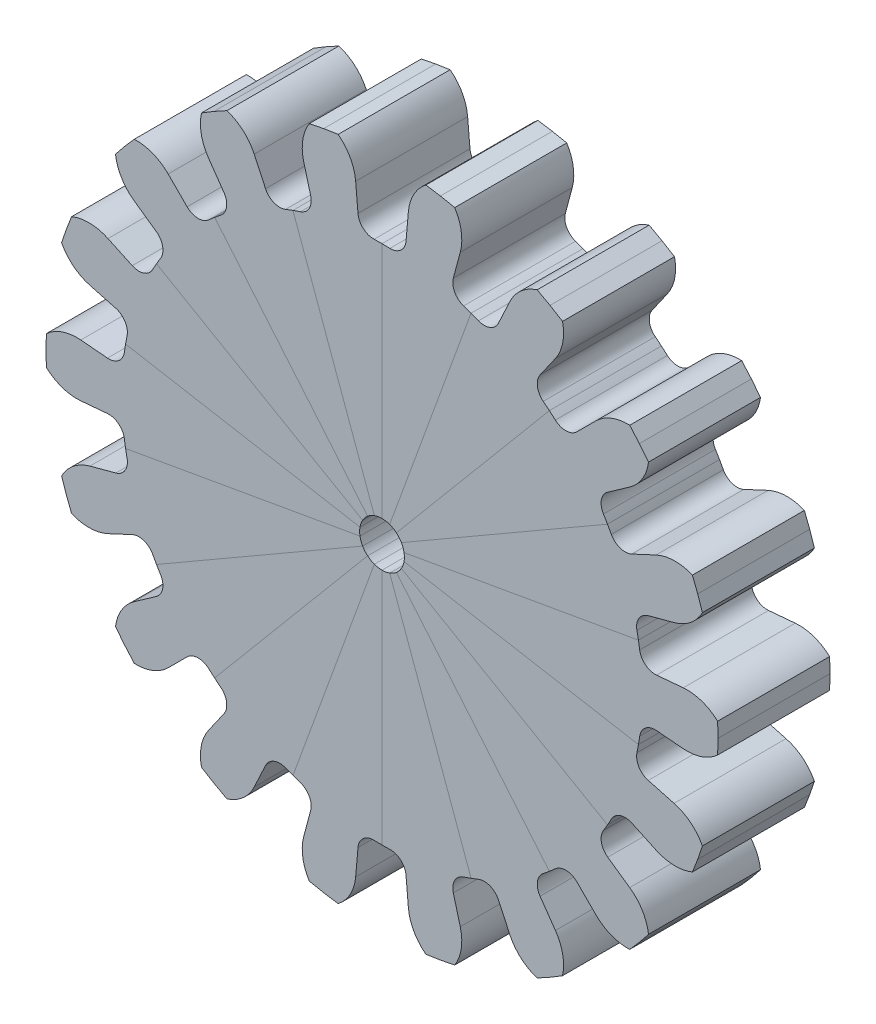
from build123d import *

# Parameters (mm, degrees)
BOSS_EXTRU_4_DEPTH           = 5
CONG_1_R                     = 0.7
R_P_TITION_CIRCULAIRE1_COUNT = 18
ESQUISSE5_R                  = 2.5
ENL_V_MAT_EXTRU_1_DEPTH      = 3
ESQUISSE6_R                  = 1
ENL_V_MAT_EXTRU_2_DEPTH      = 2


with BuildPart() as part:
    # Esquisse4 → Boss.-Extru.4 (new body)
    with BuildSketch(Plane.XY):
        with BuildLine():
            ThreePointArc((11.580763365, -1.013185509), (11.525546513, -1.517366985), (11.448390129, -2.018660065))
            Line((11.448390129, -2.018660065), (0, 0))
            Line((0, 0), (11.448390129, 2.018660065))
            ThreePointArc((11.448390129, 2.018660065), (11.525546513, 1.517366985), (11.580763365, 1.013185509))
            Line((11.580763365, 1.013185509), (13.448628424, 1.176602527))
            ThreePointArc((13.448628424, 1.176602527), (14.27213386, 1.077180815), (14.985723324, 0.65429081))
            Line((14.985723324, 0.65429081), (15, 0))
            Line((15, 0), (14.985723324, -0.65429081))
            ThreePointArc((14.985723324, -0.65429081), (14.27213386, -1.077180815), (13.448628424, -1.176602527))
            Line((13.448628424, -1.176602527), (11.580763365, -1.013185509))
        make_face()
    extrude(amount=BOSS_EXTRU_4_DEPTH)

    # Congé1
    cong_1_edges = [part.edges().sort_by_distance(p)[0] for p in [
        (11.580763365, 1.013185509, 2.5),
        (11.580763365, -1.013185509, 2.5),
    ]]
    fillet(cong_1_edges, radius=CONG_1_R)


with BuildPart() as r_p_tition_circulaire1_1:
    # Répétition circulaire1: pattern copy
    add(part.part.rotate(Axis((0, 0, 0), (0, 0, 1)), 1 * 360 / R_P_TITION_CIRCULAIRE1_COUNT))


with BuildPart() as r_p_tition_circulaire1_2:
    # Répétition circulaire1: pattern copy
    add(part.part.rotate(Axis((0, 0, 0), (0, 0, 1)), 2 * 360 / R_P_TITION_CIRCULAIRE1_COUNT))


with BuildPart() as r_p_tition_circulaire1_3:
    # Répétition circulaire1: pattern copy
    add(part.part.rotate(Axis((0, 0, 0), (0, 0, 1)), 3 * 360 / R_P_TITION_CIRCULAIRE1_COUNT))


with BuildPart() as r_p_tition_circulaire1_4:
    # Répétition circulaire1: pattern copy
    add(part.part.rotate(Axis((0, 0, 0), (0, 0, 1)), 4 * 360 / R_P_TITION_CIRCULAIRE1_COUNT))


with BuildPart() as r_p_tition_circulaire1_5:
    # Répétition circulaire1: pattern copy
    add(part.part.rotate(Axis((0, 0, 0), (0, 0, 1)), 5 * 360 / R_P_TITION_CIRCULAIRE1_COUNT))


with BuildPart() as r_p_tition_circulaire1_6:
    # Répétition circulaire1: pattern copy
    add(part.part.rotate(Axis((0, 0, 0), (0, 0, 1)), 6 * 360 / R_P_TITION_CIRCULAIRE1_COUNT))


with BuildPart() as r_p_tition_circulaire1_7:
    # Répétition circulaire1: pattern copy
    add(part.part.rotate(Axis((0, 0, 0), (0, 0, 1)), 7 * 360 / R_P_TITION_CIRCULAIRE1_COUNT))


with BuildPart() as r_p_tition_circulaire1_8:
    # Répétition circulaire1: pattern copy
    add(part.part.rotate(Axis((0, 0, 0), (0, 0, 1)), 8 * 360 / R_P_TITION_CIRCULAIRE1_COUNT))


with BuildPart() as r_p_tition_circulaire1_9:
    # Répétition circulaire1: pattern copy
    add(part.part.rotate(Axis((0, 0, 0), (0, 0, 1)), 9 * 360 / R_P_TITION_CIRCULAIRE1_COUNT))


with BuildPart() as r_p_tition_circulaire1_10:
    # Répétition circulaire1: pattern copy
    add(part.part.rotate(Axis((0, 0, 0), (0, 0, 1)), 10 * 360 / R_P_TITION_CIRCULAIRE1_COUNT))


with BuildPart() as r_p_tition_circulaire1_11:
    # Répétition circulaire1: pattern copy
    add(part.part.rotate(Axis((0, 0, 0), (0, 0, 1)), 11 * 360 / R_P_TITION_CIRCULAIRE1_COUNT))


with BuildPart() as r_p_tition_circulaire1_12:
    # Répétition circulaire1: pattern copy
    add(part.part.rotate(Axis((0, 0, 0), (0, 0, 1)), 12 * 360 / R_P_TITION_CIRCULAIRE1_COUNT))


with BuildPart() as r_p_tition_circulaire1_13:
    # Répétition circulaire1: pattern copy
    add(part.part.rotate(Axis((0, 0, 0), (0, 0, 1)), 13 * 360 / R_P_TITION_CIRCULAIRE1_COUNT))


with BuildPart() as r_p_tition_circulaire1_14:
    # Répétition circulaire1: pattern copy
    add(part.part.rotate(Axis((0, 0, 0), (0, 0, 1)), 14 * 360 / R_P_TITION_CIRCULAIRE1_COUNT))


with BuildPart() as r_p_tition_circulaire1_15:
    # Répétition circulaire1: pattern copy
    add(part.part.rotate(Axis((0, 0, 0), (0, 0, 1)), 15 * 360 / R_P_TITION_CIRCULAIRE1_COUNT))


with BuildPart() as r_p_tition_circulaire1_16:
    # Répétition circulaire1: pattern copy
    add(part.part.rotate(Axis((0, 0, 0), (0, 0, 1)), 16 * 360 / R_P_TITION_CIRCULAIRE1_COUNT))


with BuildPart() as r_p_tition_circulaire1_17:
    # Répétition circulaire1: pattern copy
    add(part.part.rotate(Axis((0, 0, 0), (0, 0, 1)), 17 * 360 / R_P_TITION_CIRCULAIRE1_COUNT))


with BuildPart() as enl_v_mat_extru_1_tool:
    # Esquisse5 → Enlèv. mat.-Extru.1 (new body)
    with BuildSketch(Plane(origin=(0, 0, 0), x_dir=(-1, 0, 0), z_dir=(0, 0, -1))):
        Circle(ESQUISSE5_R)
    extrude(amount=-ENL_V_MAT_EXTRU_1_DEPTH)


with BuildPart() as part_1:
    add(part.part)

    # Enlèv. mat.-Extru.1: cut by enl_v_mat_extru_1_tool
    add(enl_v_mat_extru_1_tool.part, mode=Mode.SUBTRACT)


with BuildPart() as r_p_tition_circulaire1_1_1:
    add(r_p_tition_circulaire1_1.part)

    # Enlèv. mat.-Extru.1: cut by enl_v_mat_extru_1_tool
    add(enl_v_mat_extru_1_tool.part, mode=Mode.SUBTRACT)


with BuildPart() as r_p_tition_circulaire1_2_1:
    add(r_p_tition_circulaire1_2.part)

    # Enlèv. mat.-Extru.1: cut by enl_v_mat_extru_1_tool
    add(enl_v_mat_extru_1_tool.part, mode=Mode.SUBTRACT)


with BuildPart() as r_p_tition_circulaire1_3_1:
    add(r_p_tition_circulaire1_3.part)

    # Enlèv. mat.-Extru.1: cut by enl_v_mat_extru_1_tool
    add(enl_v_mat_extru_1_tool.part, mode=Mode.SUBTRACT)


with BuildPart() as r_p_tition_circulaire1_4_1:
    add(r_p_tition_circulaire1_4.part)

    # Enlèv. mat.-Extru.1: cut by enl_v_mat_extru_1_tool
    add(enl_v_mat_extru_1_tool.part, mode=Mode.SUBTRACT)


with BuildPart() as r_p_tition_circulaire1_5_1:
    add(r_p_tition_circulaire1_5.part)

    # Enlèv. mat.-Extru.1: cut by enl_v_mat_extru_1_tool
    add(enl_v_mat_extru_1_tool.part, mode=Mode.SUBTRACT)


with BuildPart() as r_p_tition_circulaire1_6_1:
    add(r_p_tition_circulaire1_6.part)

    # Enlèv. mat.-Extru.1: cut by enl_v_mat_extru_1_tool
    add(enl_v_mat_extru_1_tool.part, mode=Mode.SUBTRACT)


with BuildPart() as r_p_tition_circulaire1_7_1:
    add(r_p_tition_circulaire1_7.part)

    # Enlèv. mat.-Extru.1: cut by enl_v_mat_extru_1_tool
    add(enl_v_mat_extru_1_tool.part, mode=Mode.SUBTRACT)


with BuildPart() as r_p_tition_circulaire1_8_1:
    add(r_p_tition_circulaire1_8.part)

    # Enlèv. mat.-Extru.1: cut by enl_v_mat_extru_1_tool
    add(enl_v_mat_extru_1_tool.part, mode=Mode.SUBTRACT)


with BuildPart() as r_p_tition_circulaire1_9_1:
    add(r_p_tition_circulaire1_9.part)

    # Enlèv. mat.-Extru.1: cut by enl_v_mat_extru_1_tool
    add(enl_v_mat_extru_1_tool.part, mode=Mode.SUBTRACT)


with BuildPart() as r_p_tition_circulaire1_10_1:
    add(r_p_tition_circulaire1_10.part)

    # Enlèv. mat.-Extru.1: cut by enl_v_mat_extru_1_tool
    add(enl_v_mat_extru_1_tool.part, mode=Mode.SUBTRACT)


with BuildPart() as r_p_tition_circulaire1_11_1:
    add(r_p_tition_circulaire1_11.part)

    # Enlèv. mat.-Extru.1: cut by enl_v_mat_extru_1_tool
    add(enl_v_mat_extru_1_tool.part, mode=Mode.SUBTRACT)


with BuildPart() as r_p_tition_circulaire1_12_1:
    add(r_p_tition_circulaire1_12.part)

    # Enlèv. mat.-Extru.1: cut by enl_v_mat_extru_1_tool
    add(enl_v_mat_extru_1_tool.part, mode=Mode.SUBTRACT)


with BuildPart() as r_p_tition_circulaire1_13_1:
    add(r_p_tition_circulaire1_13.part)

    # Enlèv. mat.-Extru.1: cut by enl_v_mat_extru_1_tool
    add(enl_v_mat_extru_1_tool.part, mode=Mode.SUBTRACT)


with BuildPart() as r_p_tition_circulaire1_14_1:
    add(r_p_tition_circulaire1_14.part)

    # Enlèv. mat.-Extru.1: cut by enl_v_mat_extru_1_tool
    add(enl_v_mat_extru_1_tool.part, mode=Mode.SUBTRACT)


with BuildPart() as r_p_tition_circulaire1_15_1:
    add(r_p_tition_circulaire1_15.part)

    # Enlèv. mat.-Extru.1: cut by enl_v_mat_extru_1_tool
    add(enl_v_mat_extru_1_tool.part, mode=Mode.SUBTRACT)


with BuildPart() as r_p_tition_circulaire1_16_1:
    add(r_p_tition_circulaire1_16.part)

    # Enlèv. mat.-Extru.1: cut by enl_v_mat_extru_1_tool
    add(enl_v_mat_extru_1_tool.part, mode=Mode.SUBTRACT)


with BuildPart() as r_p_tition_circulaire1_17_1:
    add(r_p_tition_circulaire1_17.part)

    # Enlèv. mat.-Extru.1: cut by enl_v_mat_extru_1_tool
    add(enl_v_mat_extru_1_tool.part, mode=Mode.SUBTRACT)


with BuildPart() as enl_v_mat_extru_2_tool:
    # Esquisse6 → Enlèv. mat.-Extru.2 (new body)
    with BuildSketch(Plane.XY.offset(5)):
        Circle(ESQUISSE6_R)
    extrude(amount=-ENL_V_MAT_EXTRU_2_DEPTH)


with BuildPart() as part_2:
    add(part_1.part)

    # Enlèv. mat.-Extru.2: cut by enl_v_mat_extru_2_tool
    add(enl_v_mat_extru_2_tool.part, mode=Mode.SUBTRACT)


with BuildPart() as r_p_tition_circulaire1_1_2:
    add(r_p_tition_circulaire1_1_1.part)

    # Enlèv. mat.-Extru.2: cut by enl_v_mat_extru_2_tool
    add(enl_v_mat_extru_2_tool.part, mode=Mode.SUBTRACT)


with BuildPart() as r_p_tition_circulaire1_2_2:
    add(r_p_tition_circulaire1_2_1.part)

    # Enlèv. mat.-Extru.2: cut by enl_v_mat_extru_2_tool
    add(enl_v_mat_extru_2_tool.part, mode=Mode.SUBTRACT)


with BuildPart() as r_p_tition_circulaire1_3_2:
    add(r_p_tition_circulaire1_3_1.part)

    # Enlèv. mat.-Extru.2: cut by enl_v_mat_extru_2_tool
    add(enl_v_mat_extru_2_tool.part, mode=Mode.SUBTRACT)


with BuildPart() as r_p_tition_circulaire1_4_2:
    add(r_p_tition_circulaire1_4_1.part)

    # Enlèv. mat.-Extru.2: cut by enl_v_mat_extru_2_tool
    add(enl_v_mat_extru_2_tool.part, mode=Mode.SUBTRACT)


with BuildPart() as r_p_tition_circulaire1_5_2:
    add(r_p_tition_circulaire1_5_1.part)

    # Enlèv. mat.-Extru.2: cut by enl_v_mat_extru_2_tool
    add(enl_v_mat_extru_2_tool.part, mode=Mode.SUBTRACT)


with BuildPart() as r_p_tition_circulaire1_6_2:
    add(r_p_tition_circulaire1_6_1.part)

    # Enlèv. mat.-Extru.2: cut by enl_v_mat_extru_2_tool
    add(enl_v_mat_extru_2_tool.part, mode=Mode.SUBTRACT)


with BuildPart() as r_p_tition_circulaire1_7_2:
    add(r_p_tition_circulaire1_7_1.part)

    # Enlèv. mat.-Extru.2: cut by enl_v_mat_extru_2_tool
    add(enl_v_mat_extru_2_tool.part, mode=Mode.SUBTRACT)


with BuildPart() as r_p_tition_circulaire1_8_2:
    add(r_p_tition_circulaire1_8_1.part)

    # Enlèv. mat.-Extru.2: cut by enl_v_mat_extru_2_tool
    add(enl_v_mat_extru_2_tool.part, mode=Mode.SUBTRACT)


with BuildPart() as r_p_tition_circulaire1_9_2:
    add(r_p_tition_circulaire1_9_1.part)

    # Enlèv. mat.-Extru.2: cut by enl_v_mat_extru_2_tool
    add(enl_v_mat_extru_2_tool.part, mode=Mode.SUBTRACT)


with BuildPart() as r_p_tition_circulaire1_10_2:
    add(r_p_tition_circulaire1_10_1.part)

    # Enlèv. mat.-Extru.2: cut by enl_v_mat_extru_2_tool
    add(enl_v_mat_extru_2_tool.part, mode=Mode.SUBTRACT)


with BuildPart() as r_p_tition_circulaire1_11_2:
    add(r_p_tition_circulaire1_11_1.part)

    # Enlèv. mat.-Extru.2: cut by enl_v_mat_extru_2_tool
    add(enl_v_mat_extru_2_tool.part, mode=Mode.SUBTRACT)


with BuildPart() as r_p_tition_circulaire1_12_2:
    add(r_p_tition_circulaire1_12_1.part)

    # Enlèv. mat.-Extru.2: cut by enl_v_mat_extru_2_tool
    add(enl_v_mat_extru_2_tool.part, mode=Mode.SUBTRACT)


with BuildPart() as r_p_tition_circulaire1_13_2:
    add(r_p_tition_circulaire1_13_1.part)

    # Enlèv. mat.-Extru.2: cut by enl_v_mat_extru_2_tool
    add(enl_v_mat_extru_2_tool.part, mode=Mode.SUBTRACT)


with BuildPart() as r_p_tition_circulaire1_14_2:
    add(r_p_tition_circulaire1_14_1.part)

    # Enlèv. mat.-Extru.2: cut by enl_v_mat_extru_2_tool
    add(enl_v_mat_extru_2_tool.part, mode=Mode.SUBTRACT)


with BuildPart() as r_p_tition_circulaire1_15_2:
    add(r_p_tition_circulaire1_15_1.part)

    # Enlèv. mat.-Extru.2: cut by enl_v_mat_extru_2_tool
    add(enl_v_mat_extru_2_tool.part, mode=Mode.SUBTRACT)


with BuildPart() as r_p_tition_circulaire1_16_2:
    add(r_p_tition_circulaire1_16_1.part)

    # Enlèv. mat.-Extru.2: cut by enl_v_mat_extru_2_tool
    add(enl_v_mat_extru_2_tool.part, mode=Mode.SUBTRACT)


with BuildPart() as r_p_tition_circulaire1_17_2:
    add(r_p_tition_circulaire1_17_1.part)

    # Enlèv. mat.-Extru.2: cut by enl_v_mat_extru_2_tool
    add(enl_v_mat_extru_2_tool.part, mode=Mode.SUBTRACT)


solid = Compound([part_2.part, r_p_tition_circulaire1_1_2.part, r_p_tition_circulaire1_2_2.part, r_p_tition_circulaire1_3_2.part, r_p_tition_circulaire1_4_2.part, r_p_tition_circulaire1_5_2.part, r_p_tition_circulaire1_6_2.part, r_p_tition_circulaire1_7_2.part, r_p_tition_circulaire1_8_2.part, r_p_tition_circulaire1_9_2.part, r_p_tition_circulaire1_10_2.part, r_p_tition_circulaire1_11_2.part, r_p_tition_circulaire1_12_2.part, r_p_tition_circulaire1_13_2.part, r_p_tition_circulaire1_14_2.part, r_p_tition_circulaire1_15_2.part, r_p_tition_circulaire1_16_2.part, r_p_tition_circulaire1_17_2.part])
